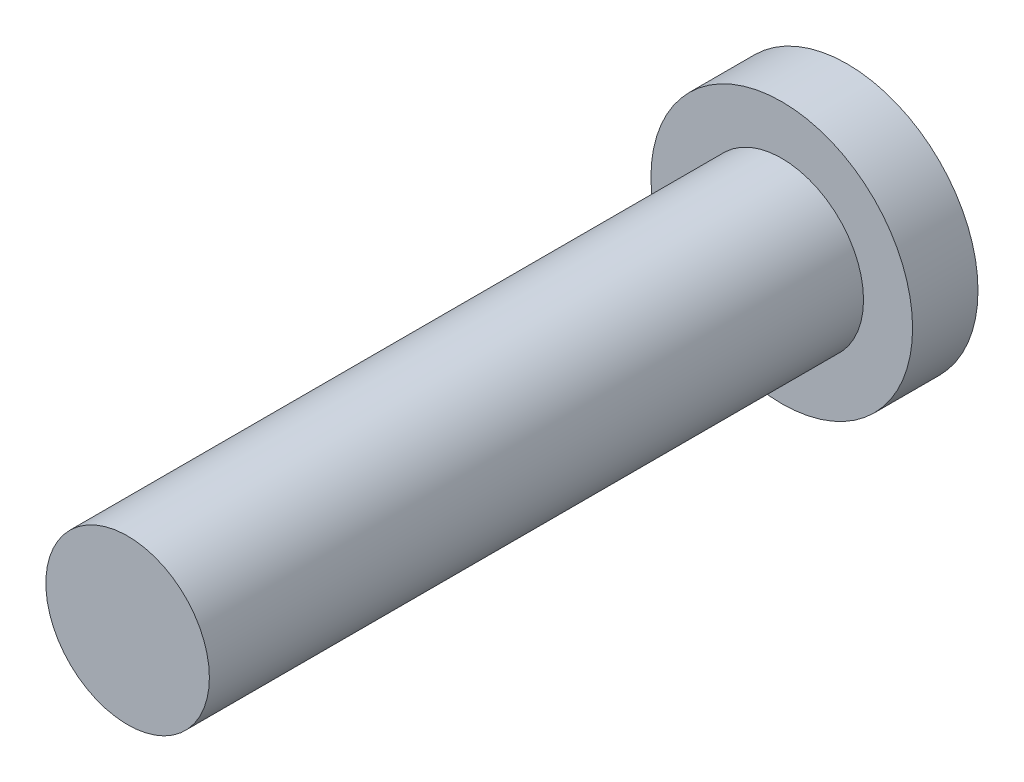
from build123d import *

# Parameters (mm, degrees)
SKETCH_1_R      = 4
EXTRUDE_1_DEPTH = 2
SKETCH_2_R      = 2.5
EXTRUDE_2_DEPTH = 20


with BuildPart() as part:
    # 草图1 → 凸台-拉伸1 (new body)
    with BuildSketch(Plane.XY):
        Circle(SKETCH_1_R)
    extrude(amount=EXTRUDE_1_DEPTH)

    # 草图2 → 凸台-拉伸2 (add)
    with BuildSketch(Plane.XY.offset(2)):
        Circle(SKETCH_2_R)
    extrude(amount=EXTRUDE_2_DEPTH)


solid = part.part
